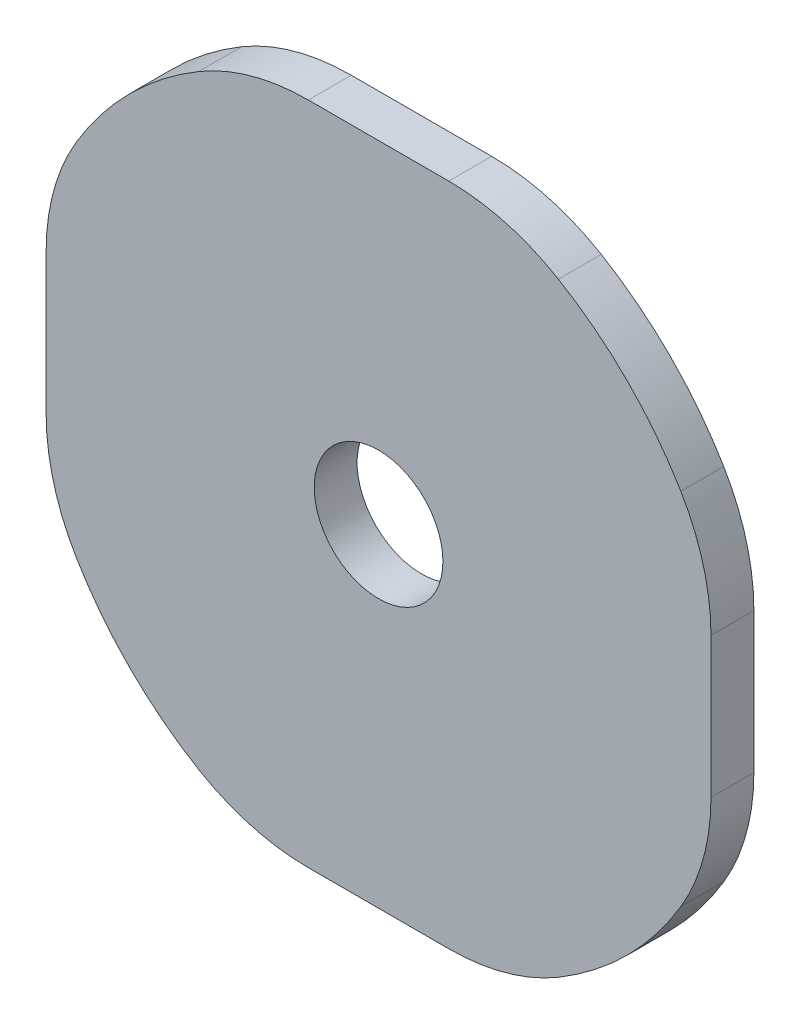
from build123d import *

# Parameters (mm, degrees)
ESQUISSE1_R             = 16.4
BOSS_EXTRU_1_DEPTH      = 2
ESQUISSE3_R             = 3
ENL_V_MAT_EXTRU_1_DEPTH = 3
ESQUISSE4_W             = 72.110421533
ESQUISSE4_H             = 46.707886675
ESQUISSE4_W_2           = 31
ESQUISSE4_H_2           = 31
ENL_V_MAT_EXTRU_2_DEPTH = 10
CONG_1_R                = 10


with BuildPart() as part:
    # Esquisse1 → Boss.-Extru.1 (new body)
    with BuildSketch(Plane.XY):
        Circle(ESQUISSE1_R)
    extrude(amount=BOSS_EXTRU_1_DEPTH)

    # Esquisse3 → Enlèv. mat.-Extru.1 (cut, through all)
    with BuildSketch(Plane.XY.offset(2)):
        Circle(ESQUISSE3_R)
    extrude(amount=-ENL_V_MAT_EXTRU_1_DEPTH, mode=Mode.SUBTRACT)

    # Esquisse4 → Enlèv. mat.-Extru.2 (cut)
    with BuildSketch(Plane(origin=(0, 0, 0), x_dir=(-1, 0, 0), z_dir=(0, 0, -1))):
        with Locations((-0.063033586, -0.977020572)):
            Rectangle(ESQUISSE4_W, ESQUISSE4_H)
        Rectangle(ESQUISSE4_W_2, ESQUISSE4_H_2, mode=Mode.SUBTRACT)
    extrude(amount=-ENL_V_MAT_EXTRU_2_DEPTH, mode=Mode.SUBTRACT)

    # Congé1
    cong_1_edges = [part.edges().sort_by_distance(p)[0] for p in [
        (15.5, -5.35817133, 1),
        (15.5, 5.35817133, 1),
        (5.35817133, 15.5, 1),
        (-5.35817133, 15.5, 1),
        (-15.5, 5.35817133, 1),
        (-15.5, -5.35817133, 1),
        (-5.35817133, -15.5, 1),
        (5.35817133, -15.5, 1),
    ]]
    fillet(cong_1_edges, radius=CONG_1_R)


solid = part.part
